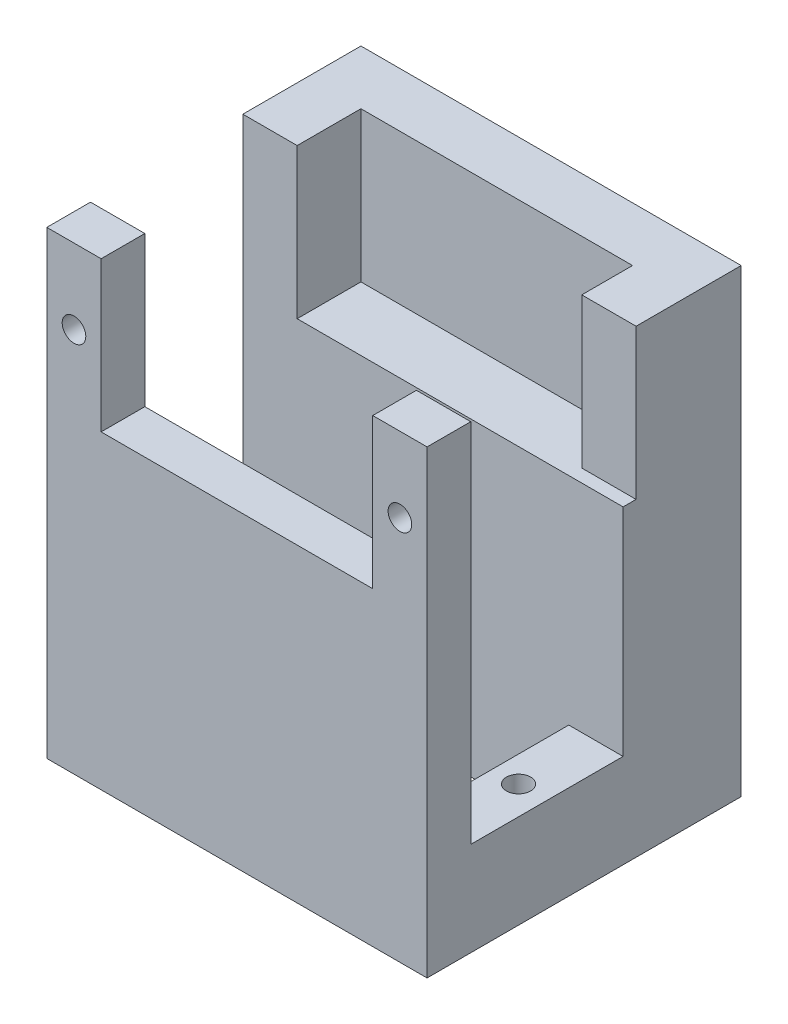
from build123d import *

# Parameters (mm, degrees)
SKETCH1_W           = 32.2
SKETCH1_H           = 26.6
SKETCH1_W_2         = 15.5
SKETCH1_H_2         = 12.9
BOSS_EXTRUDE1_DEPTH = 4.25
SKETCH1_3_W         = 32.2
SKETCH1_3_H         = 26.6
BOSS_EXTRUDE2_DEPTH = 3.7
SKETCH2_R           = 1.025
CUT_EXTRUDE1_DEPTH  = 5
SKETCH3_W           = 32.2
SKETCH3_H           = 3.7
SKETCH3_H_2         = 10
BOSS_EXTRUDE3_DEPTH = 18.3
SKETCH4_W           = 4.6
SKETCH4_H           = 3.7
BOSS_EXTRUDE4_DEPTH = 12.7
CUT_EXTRUDE2_REACH  = 50.569
SKETCH5_R           = 1


with BuildPart() as part:
    # Sketch1 → Boss-Extrude1 (new body)
    with BuildSketch(Plane(origin=(0, 0, 0), x_dir=(1, 0, 0), z_dir=(0, 1, 0))):
        with Locations((-5.05, 3.15)):
            Rectangle(SKETCH1_W, SKETCH1_H)
        with Locations((-1.3, 0)):
            Rectangle(SKETCH1_W_2, SKETCH1_H_2, mode=Mode.SUBTRACT)
    extrude(amount=-BOSS_EXTRUDE1_DEPTH)

    # Sketch1_3 → Boss-Extrude2 (add)
    with BuildSketch(Plane(origin=(0, 0, 0), x_dir=(1, 0, 0), z_dir=(0, 1, 0))):
        with Locations((-5.05, 3.15)):
            Rectangle(SKETCH1_3_W, SKETCH1_3_H)
        Polygon((-16.55, -6.45), (-16.55, 6.45), (-9.05, 6.45), (2.5e-08, 6.45), (6.45, 6.45), (6.45, 0), (6.45, -6.45), (3.5e-08, -6.45), (-9.05, -6.45), align=None, mode=Mode.SUBTRACT)
    extrude(amount=BOSS_EXTRUDE2_DEPTH)

    # Sketch2 → Cut-Extrude1 (cut)
    with BuildSketch(Plane(origin=(0, 3.7, 0), x_dir=(1, 0, 0), z_dir=(0, 1, 0))):
        with Locations((-18.75, 0)):
            Circle(SKETCH2_R)
        with Locations((8.65, 0)):
            Circle(SKETCH2_R)
    extrude(amount=-CUT_EXTRUDE1_DEPTH, mode=Mode.SUBTRACT)

    # Sketch3 → Boss-Extrude3 (add)
    with BuildSketch(Plane(origin=(0, 3.7, 0), x_dir=(1, 0, 0), z_dir=(0, 1, 0))):
        with Locations((-5.05, -8.3)):
            Rectangle(SKETCH3_W, SKETCH3_H)
        with Locations((-5.05, 11.45)):
            Rectangle(SKETCH3_W, SKETCH3_H_2)
    extrude(amount=BOSS_EXTRUDE3_DEPTH)

    # Sketch4 → Boss-Extrude4 (add)
    with BuildSketch(Plane(origin=(0, 22, 0), x_dir=(1, 0, 0), z_dir=(0, 1, 0))):
        Polygon((-21.15, 16.45), (-16.55, 16.45), (6.45, 16.45), (11.05, 16.45), (11.05, 7.55), (6.45, 7.55), (6.45, 11.85), (-16.55, 11.85), (-16.55, 6.45), (-21.15, 6.45), align=None)
        with Locations((-18.85, -8.3)):
            Rectangle(SKETCH4_W, SKETCH4_H)
        with Locations((8.75, -8.3)):
            Rectangle(SKETCH4_W, SKETCH4_H)
    extrude(amount=BOSS_EXTRUDE4_DEPTH)

    # Sketch5 → Cut-Extrude2 (cut, up to next)
    with BuildSketch(Plane.XY.offset(10.15), mode=Mode.PRIVATE) as cut_extrude2_sk1:
        with Locations((-18.85, 28.35)):
            Circle(SKETCH5_R)
    cut_extrude2_tool1 = extrude(cut_extrude2_sk1.sketch, amount=-CUT_EXTRUDE2_REACH, mode=Mode.PRIVATE) & part.part
    # Sketch5 → Cut-Extrude2 (cut, up to next)
    with BuildSketch(Plane.XY.offset(10.15), mode=Mode.PRIVATE) as cut_extrude2_sk2:
        with Locations((8.75, 28.35)):
            Circle(SKETCH5_R)
    cut_extrude2_tool2 = extrude(cut_extrude2_sk2.sketch, amount=-CUT_EXTRUDE2_REACH, mode=Mode.PRIVATE) & part.part
    add(cut_extrude2_tool1.solids().sort_by_distance((-18.85, 28.35, 10.15))[0], mode=Mode.SUBTRACT)
    add(cut_extrude2_tool2.solids().sort_by_distance((8.75, 28.35, 10.15))[0], mode=Mode.SUBTRACT)


solid = part.part
